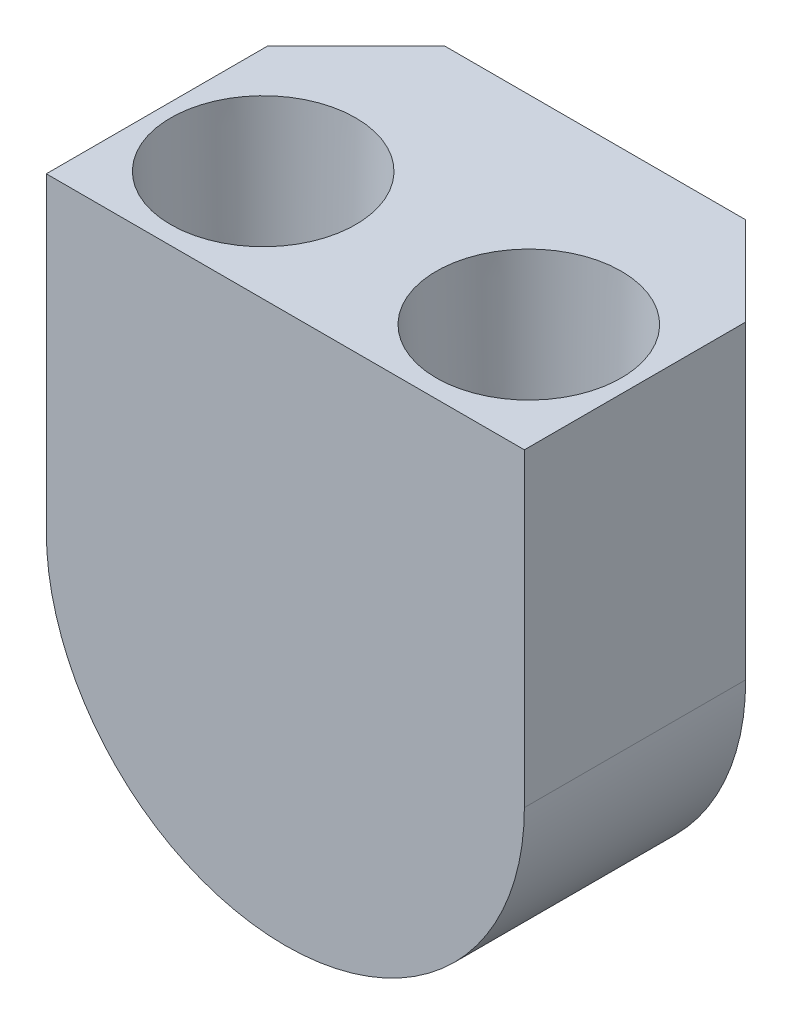
from build123d import *

# Parameters (mm, degrees)
BOSS_EXTRUDE1_DEPTH = 8.89
CHAMFER1_SIZE       = 2.54
HOLE1_AT_2_COUNT    = 2
HOLE1_AT_2_PITCH    = 7.62


with BuildPart() as part:
    # Sketch1 → Boss-Extrude1 (new body)
    with BuildSketch(Plane.XY):
        with BuildLine():
            Line((6.020580432, 9.158318359), (-7.695419568, 9.158318359))
            Line((-7.695419568, 9.158318359), (-7.695419568, 0.268318359))
            ThreePointArc((-7.695419568, 0.268318359), (-0.837419568, -6.589681641), (6.020580432, 0.268318359))
            Line((6.020580432, 0.268318359), (6.020580432, 9.158318359))
        make_face()
    extrude(amount=-BOSS_EXTRUDE1_DEPTH)

    # Chamfer1
    chamfer1_edges = [part.edges().sort_by_distance(p)[0] for p in [
        (-0.837419568, -6.589681641, -8.89),
        (6.020580432, 4.713318359, -8.89),
        (-7.695419568, 4.713318359, -8.89),
    ]]
    chamfer(chamfer1_edges, length=CHAMFER1_SIZE)

    # Sketch3 → Hole1 (revolve, cut)
    with BuildSketch(Plane(origin=(2.972580432, 9.158318359, -3.175), x_dir=(0, 0, 1), z_dir=(1, 0, 0))):
        Polygon((0, 0), (0, 3.81), (2.5273, 3.81), (2.6543, 0), align=None)
    hole1 = revolve(axis=Axis((2.972580432, -100.841681641, -3.175), (0, 1, 0)), mode=Mode.SUBTRACT)

    # Hole1 at 2: Hole1 ×2
    with Locations(*[(-i * HOLE1_AT_2_PITCH, 0, 0) for i in range(1, HOLE1_AT_2_COUNT)]):
        add(hole1, mode=Mode.SUBTRACT)


solid = part.part
